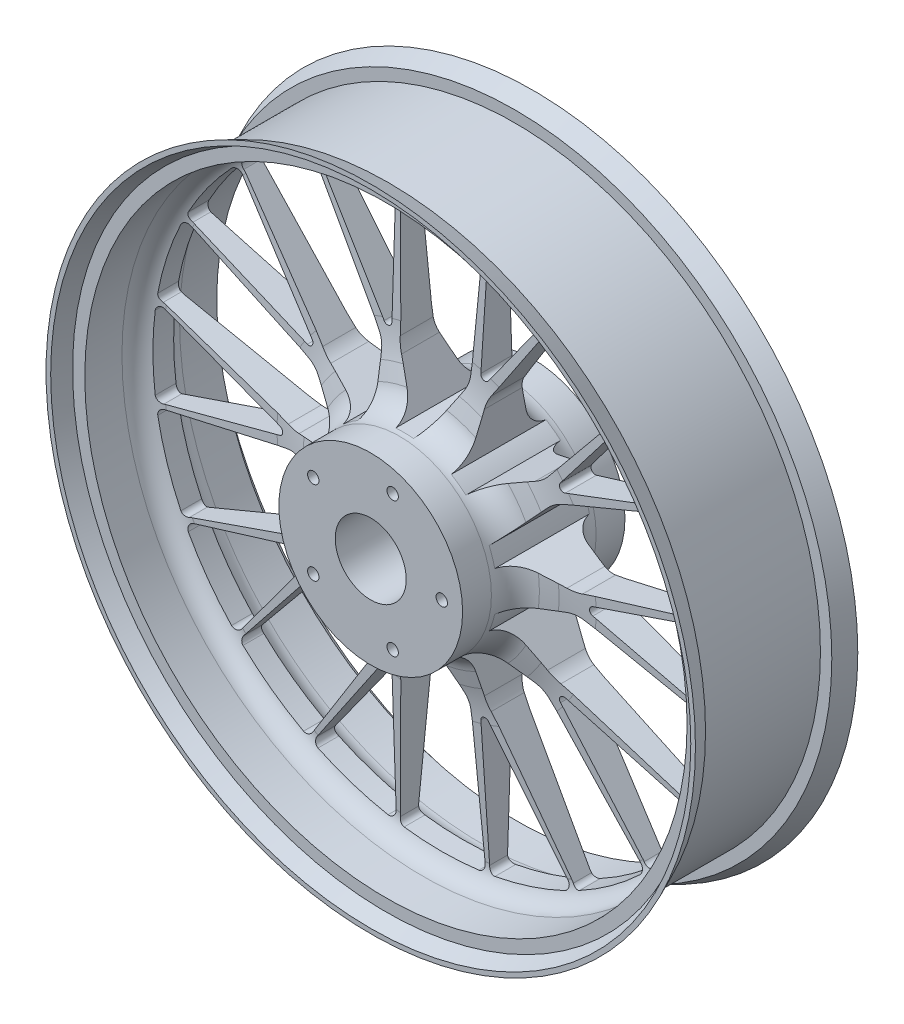
from build123d import *

# Parameters (mm, degrees)
SKETCH1_R           = 228.6
SKETCH1_R_2         = 25
SKETCH1_R_3         = 4
BOSS_EXTRUDE1_DEPTH = 57.15


with BuildPart() as part:
    # Sketch1 → Boss-Extrude1 (new body, symmetric)
    with BuildSketch(Plane.XY):
        Circle(SKETCH1_R)
        Circle(SKETCH1_R_2, mode=Mode.SUBTRACT)
        with Locations((15.45085, 47.552826)):
            Circle(SKETCH1_R_3, mode=Mode.SUBTRACT)
        with Locations((50, 0)):
            Circle(SKETCH1_R_3, mode=Mode.SUBTRACT)
        with Locations((15.45085, -47.552826)):
            Circle(SKETCH1_R_3, mode=Mode.SUBTRACT)
        with Locations((-40.45085, -29.389263)):
            Circle(SKETCH1_R_3, mode=Mode.SUBTRACT)
        with Locations((-40.45085, 29.389263)):
            Circle(SKETCH1_R_3, mode=Mode.SUBTRACT)
        with BuildLine():
            Line((-29.808072, 197.311036), (-24.75602, 100.912126))
            ThreePointArc((-24.75602, 100.912126), (-23.959824, 96.278538), (-22.103937, 91.958845))
            Line((-22.103937, 91.958845), (-6.35921, 64.688179))
            ThreePointArc((-6.35921, 64.688179), (0, 65), (6.35921, 64.688179))
            Line((6.35921, 64.688179), (22.103937, 91.958845))
            ThreePointArc((22.103937, 91.958845), (23.959824, 96.278538), (24.75602, 100.912126))
            Line((24.75602, 100.912126), (29.808072, 197.311036))
            ThreePointArc((29.808072, 197.311036), (28.887709, 200.079593), (26.331899, 201.486652))
            ThreePointArc((26.331899, 201.486652), (0, 203.2), (-26.331899, 201.486652))
            ThreePointArc((-26.331899, 201.486652), (-28.887709, 200.079593), (-29.808072, 197.311036))
        make_face(mode=Mode.SUBTRACT)
        with BuildLine():
            Line((91.86128, 177.148727), (39.286619, 96.190848))
            ThreePointArc((39.286619, 96.190848), (37.2072, 91.974204), (36.169592, 87.388636))
            Line((36.169592, 87.388636), (32.878048, 56.071686))
            ThreePointArc((32.878048, 56.071686), (38.206041, 52.586105), (43.167467, 48.595986))
            Line((43.167467, 48.595986), (71.934513, 61.4039))
            ThreePointArc((71.934513, 61.4039), (75.975009, 63.807742), (79.3427, 67.088401))
            Line((79.3427, 67.088401), (140.091754, 142.107236))
            ThreePointArc((140.091754, 142.107236), (140.974482, 144.888022), (139.733836, 147.528624))
            ThreePointArc((139.733836, 147.528624), (119.437963, 164.392253), (97.127929, 178.483628))
            ThreePointArc((97.127929, 178.483628), (94.233187, 178.84756), (91.86128, 177.148727))
        make_face(mode=Mode.SUBTRACT)
        with BuildLine():
            Line((-31.301343, 105.619631), (-32.875918, 195.826934))
            ThreePointArc((-32.875918, 195.826934), (-34.34903, 198.858401), (-37.615776, 199.68799))
            ThreePointArc((-37.615776, 199.68799), (-62.772389, 193.261137), (-86.904095, 183.678846))
            ThreePointArc((-86.904095, 183.678846), (-89.059737, 181.088459), (-88.471019, 177.770281))
            Line((-88.471019, 177.770281), (-36.758343, 103.846544))
            ThreePointArc((-36.758343, 103.846544), (-35.2528, 102.722302), (-33.373835, 102.714104))
            ThreePointArc((-33.373835, 102.714104), (-31.85854, 103.825164), (-31.301343, 105.619631))
        make_face(mode=Mode.SUBTRACT)
        with BuildLine():
            Line((36.758343, 103.846544), (88.507008, 177.751297))
            ThreePointArc((88.507008, 177.751297), (89.097086, 181.069679), (86.941853, 183.660976))
            ThreePointArc((86.941853, 183.660976), (62.812117, 193.248229), (37.656827, 199.680253))
            ThreePointArc((37.656827, 199.680253), (34.390285, 198.851641), (32.916192, 195.821138))
            Line((32.916192, 195.821138), (31.301343, 105.619631))
            ThreePointArc((31.301343, 105.619631), (31.85854, 103.825164), (33.373835, 102.714104))
            ThreePointArc((33.373835, 102.714104), (35.2528, 102.722302), (36.758343, 103.846544))
        make_face(mode=Mode.SUBTRACT)
        with BuildLine():
            Line((178.442745, 89.321625), (88.323104, 54.727936))
            ThreePointArc((88.323104, 54.727936), (84.162338, 52.538851), (80.627566, 49.438939))
            Line((80.627566, 49.438939), (59.55701, 26.037715))
            ThreePointArc((59.55701, 26.037715), (61.818674, 20.086105), (63.487218, 13.941778))
            Line((63.487218, 13.941778), (94.288551, 7.394753))
            ThreePointArc((94.288551, 7.394753), (98.970324, 6.964558), (103.623165, 7.639188))
            Line((103.623165, 7.639188), (196.865147, 32.623302))
            ThreePointArc((196.865147, 32.623302), (199.213794, 34.354151), (199.762198, 37.219676))
            ThreePointArc((199.762198, 37.219676), (193.254684, 62.792253), (183.48819, 87.305924))
            ThreePointArc((183.48819, 87.305924), (181.360208, 89.301838), (178.442745, 89.321625))
        make_face(mode=Mode.SUBTRACT)
        with BuildLine():
            Line((90.777591, 62.407607), (176.083264, 91.780706))
            ThreePointArc((176.083264, 91.780706), (178.511144, 94.118494), (178.29065, 97.481712))
            ThreePointArc((178.29065, 97.481712), (164.404529, 119.421065), (147.834121, 139.41059))
            ThreePointArc((147.834121, 139.41059), (144.704387, 140.660254), (141.730536, 139.074977))
            Line((141.730536, 139.074977), (87.40498, 67.049608))
            ThreePointArc((87.40498, 67.049608), (86.801001, 65.270343), (87.373835, 63.480807))
            ThreePointArc((87.373835, 63.480807), (88.898769, 62.383012), (90.777591, 62.407607))
        make_face(mode=Mode.SUBTRACT)
        with BuildLine():
            Line((196.865147, -32.623302), (103.623165, -7.639188))
            ThreePointArc((103.623165, -7.639188), (98.970324, -6.964558), (94.288551, -7.394753))
            Line((94.288551, -7.394753), (63.487218, -13.941778))
            ThreePointArc((63.487218, -13.941778), (61.818674, -20.086105), (59.55701, -26.037715))
            Line((59.55701, -26.037715), (80.627566, -49.438939))
            ThreePointArc((80.627566, -49.438939), (84.162338, -52.538851), (88.323104, -54.727936))
            Line((88.323104, -54.727936), (178.442745, -89.321625))
            ThreePointArc((178.442745, -89.321625), (181.360208, -89.301838), (183.48819, -87.305924))
            ThreePointArc((183.48819, -87.305924), (193.254684, -62.792253), (199.762198, -37.219676))
            ThreePointArc((199.762198, -37.219676), (199.213794, -34.354151), (196.865147, -32.623302))
        make_face(mode=Mode.SUBTRACT)
        with BuildLine():
            Line((110.122885, -2.868914), (196.401699, -29.246995))
            ThreePointArc((196.401699, -29.246995), (199.740012, -28.782757), (201.538478, -25.932253))
            ThreePointArc((201.538478, -25.932253), (203.199999, -0.020887), (201.543805, 25.890821))
            ThreePointArc((201.543805, 25.890821), (199.746331, 28.741432), (196.408632, 29.206901))
            Line((196.408632, 29.206901), (110.122885, 2.868914))
            ThreePointArc((110.122885, 2.868914), (108.588429, 1.784468), (108, 0))
            ThreePointArc((108, 0), (108.588429, -1.784468), (110.122885, -2.868914))
        make_face(mode=Mode.SUBTRACT)
        with BuildLine():
            Line((140.091754, -142.107236), (79.3427, -67.088401))
            ThreePointArc((79.3427, -67.088401), (75.975009, -63.807742), (71.934513, -61.4039))
            Line((71.934513, -61.4039), (43.167467, -48.595986))
            ThreePointArc((43.167467, -48.595986), (38.206041, -52.586105), (32.878048, -56.071686))
            Line((32.878048, -56.071686), (36.169592, -87.388636))
            ThreePointArc((36.169592, -87.388636), (37.2072, -91.974204), (39.286619, -96.190848))
            Line((39.286619, -96.190848), (91.86128, -177.148727))
            ThreePointArc((91.86128, -177.148727), (94.233187, -178.84756), (97.127929, -178.483628))
            ThreePointArc((97.127929, -178.483628), (119.437963, -164.392253), (139.733836, -147.528624))
            ThreePointArc((139.733836, -147.528624), (140.974482, -144.888022), (140.091754, -142.107236))
        make_face(mode=Mode.SUBTRACT)
        with BuildLine():
            Line((87.40498, -67.049608), (141.70136, -139.103338))
            ThreePointArc((141.70136, -139.103338), (144.674984, -140.689972), (147.805458, -139.440979))
            ThreePointArc((147.805458, -139.440979), (164.379976, -119.45486), (178.270606, -97.518362))
            ThreePointArc((178.270606, -97.518362), (178.491966, -94.155641), (176.065307, -91.817218))
            Line((176.065307, -91.817218), (90.777591, -62.407607))
            ThreePointArc((90.777591, -62.407607), (88.898769, -62.383012), (87.373835, -63.480807))
            ThreePointArc((87.373835, -63.480807), (86.801001, -65.270343), (87.40498, -67.049608))
        make_face(mode=Mode.SUBTRACT)
        with BuildLine():
            Line((29.808072, -197.311036), (24.75602, -100.912126))
            ThreePointArc((24.75602, -100.912126), (23.959824, -96.278538), (22.103937, -91.958845))
            Line((22.103937, -91.958845), (6.35921, -64.688179))
            ThreePointArc((6.35921, -64.688179), (0, -65), (-6.35921, -64.688179))
            Line((-6.35921, -64.688179), (-22.103937, -91.958845))
            ThreePointArc((-22.103937, -91.958845), (-23.959824, -96.278538), (-24.75602, -100.912126))
            Line((-24.75602, -100.912126), (-29.808072, -197.311036))
            ThreePointArc((-29.808072, -197.311036), (-28.887709, -200.079593), (-26.331899, -201.486652))
            ThreePointArc((-26.331899, -201.486652), (0, -203.2), (26.331899, -201.486652))
            ThreePointArc((26.331899, -201.486652), (28.887709, -200.079593), (29.808072, -197.311036))
        make_face(mode=Mode.SUBTRACT)
        with BuildLine():
            Line((31.301343, -105.619631), (32.875918, -195.826934))
            ThreePointArc((32.875918, -195.826934), (34.34903, -198.858401), (37.615776, -199.68799))
            ThreePointArc((37.615776, -199.68799), (62.772389, -193.261137), (86.904095, -183.678846))
            ThreePointArc((86.904095, -183.678846), (89.059737, -181.088459), (88.471019, -177.770281))
            Line((88.471019, -177.770281), (36.758343, -103.846544))
            ThreePointArc((36.758343, -103.846544), (35.2528, -102.722302), (33.373835, -102.714104))
            ThreePointArc((33.373835, -102.714104), (31.85854, -103.825164), (31.301343, -105.619631))
        make_face(mode=Mode.SUBTRACT)
        with BuildLine():
            Line((-91.86128, -177.148727), (-39.286619, -96.190848))
            ThreePointArc((-39.286619, -96.190848), (-37.2072, -91.974204), (-36.169592, -87.388636))
            Line((-36.169592, -87.388636), (-32.878048, -56.071686))
            ThreePointArc((-32.878048, -56.071686), (-38.206041, -52.586105), (-43.167467, -48.595986))
            Line((-43.167467, -48.595986), (-71.934513, -61.4039))
            ThreePointArc((-71.934513, -61.4039), (-75.975009, -63.807742), (-79.3427, -67.088401))
            Line((-79.3427, -67.088401), (-140.091754, -142.107236))
            ThreePointArc((-140.091754, -142.107236), (-140.974482, -144.888022), (-139.733836, -147.528624))
            ThreePointArc((-139.733836, -147.528624), (-119.437963, -164.392253), (-97.127929, -178.483628))
            ThreePointArc((-97.127929, -178.483628), (-94.233187, -178.84756), (-91.86128, -177.148727))
        make_face(mode=Mode.SUBTRACT)
        with BuildLine():
            Line((-36.758343, -103.846544), (-88.507008, -177.751297))
            ThreePointArc((-88.507008, -177.751297), (-89.097086, -181.069679), (-86.941853, -183.660976))
            ThreePointArc((-86.941853, -183.660976), (-62.812117, -193.248229), (-37.656827, -199.680253))
            ThreePointArc((-37.656827, -199.680253), (-34.390285, -198.851641), (-32.916192, -195.821138))
            Line((-32.916192, -195.821138), (-31.301343, -105.619631))
            ThreePointArc((-31.301343, -105.619631), (-31.85854, -103.825164), (-33.373835, -102.714104))
            ThreePointArc((-33.373835, -102.714104), (-35.2528, -102.722302), (-36.758343, -103.846544))
        make_face(mode=Mode.SUBTRACT)
        with BuildLine():
            Line((-178.442745, -89.321625), (-88.323104, -54.727936))
            ThreePointArc((-88.323104, -54.727936), (-84.162338, -52.538851), (-80.627566, -49.438939))
            Line((-80.627566, -49.438939), (-59.55701, -26.037715))
            ThreePointArc((-59.55701, -26.037715), (-61.818674, -20.086105), (-63.487218, -13.941778))
            Line((-63.487218, -13.941778), (-94.288551, -7.394753))
            ThreePointArc((-94.288551, -7.394753), (-98.970324, -6.964558), (-103.623165, -7.639188))
            Line((-103.623165, -7.639188), (-196.865147, -32.623302))
            ThreePointArc((-196.865147, -32.623302), (-199.213794, -34.354151), (-199.762198, -37.219676))
            ThreePointArc((-199.762198, -37.219676), (-193.254684, -62.792253), (-183.48819, -87.305924))
            ThreePointArc((-183.48819, -87.305924), (-181.360208, -89.301838), (-178.442745, -89.321625))
        make_face(mode=Mode.SUBTRACT)
        with BuildLine():
            Line((-90.777591, -62.407607), (-176.083264, -91.780706))
            ThreePointArc((-176.083264, -91.780706), (-178.511144, -94.118494), (-178.29065, -97.481712))
            ThreePointArc((-178.29065, -97.481712), (-164.404529, -119.421065), (-147.834121, -139.41059))
            ThreePointArc((-147.834121, -139.41059), (-144.704387, -140.660254), (-141.730536, -139.074977))
            Line((-141.730536, -139.074977), (-87.40498, -67.049608))
            ThreePointArc((-87.40498, -67.049608), (-86.801001, -65.270343), (-87.373835, -63.480807))
            ThreePointArc((-87.373835, -63.480807), (-88.898769, -62.383012), (-90.777591, -62.407607))
        make_face(mode=Mode.SUBTRACT)
        with BuildLine():
            Line((-196.865147, 32.623302), (-103.623165, 7.639188))
            ThreePointArc((-103.623165, 7.639188), (-98.970324, 6.964558), (-94.288551, 7.394753))
            Line((-94.288551, 7.394753), (-63.487218, 13.941778))
            ThreePointArc((-63.487218, 13.941778), (-61.818674, 20.086105), (-59.55701, 26.037715))
            Line((-59.55701, 26.037715), (-80.627566, 49.438939))
            ThreePointArc((-80.627566, 49.438939), (-84.162338, 52.538851), (-88.323104, 54.727936))
            Line((-88.323104, 54.727936), (-178.442745, 89.321625))
            ThreePointArc((-178.442745, 89.321625), (-181.360208, 89.301838), (-183.48819, 87.305924))
            ThreePointArc((-183.48819, 87.305924), (-193.254684, 62.792253), (-199.762198, 37.219676))
            ThreePointArc((-199.762198, 37.219676), (-199.213794, 34.354151), (-196.865147, 32.623302))
        make_face(mode=Mode.SUBTRACT)
        with BuildLine():
            Line((-110.122885, 2.868914), (-196.401699, 29.246995))
            ThreePointArc((-196.401699, 29.246995), (-199.740012, 28.782757), (-201.538478, 25.932253))
            ThreePointArc((-201.538478, 25.932253), (-203.199999, 0.020887), (-201.543805, -25.890821))
            ThreePointArc((-201.543805, -25.890821), (-199.746331, -28.741432), (-196.408632, -29.206901))
            Line((-196.408632, -29.206901), (-110.122885, -2.868914))
            ThreePointArc((-110.122885, -2.868914), (-108.588429, -1.784468), (-108, 0))
            ThreePointArc((-108, 0), (-108.588429, 1.784468), (-110.122885, 2.868914))
        make_face(mode=Mode.SUBTRACT)
        with BuildLine():
            Line((-140.091754, 142.107236), (-79.3427, 67.088401))
            ThreePointArc((-79.3427, 67.088401), (-75.975009, 63.807742), (-71.934513, 61.4039))
            Line((-71.934513, 61.4039), (-43.167467, 48.595986))
            ThreePointArc((-43.167467, 48.595986), (-38.206041, 52.586105), (-32.878048, 56.071686))
            Line((-32.878048, 56.071686), (-36.169592, 87.388636))
            ThreePointArc((-36.169592, 87.388636), (-37.2072, 91.974204), (-39.286619, 96.190848))
            Line((-39.286619, 96.190848), (-91.86128, 177.148727))
            ThreePointArc((-91.86128, 177.148727), (-94.233187, 178.84756), (-97.127929, 178.483628))
            ThreePointArc((-97.127929, 178.483628), (-119.437963, 164.392253), (-139.733836, 147.528624))
            ThreePointArc((-139.733836, 147.528624), (-140.974482, 144.888022), (-140.091754, 142.107236))
        make_face(mode=Mode.SUBTRACT)
        with BuildLine():
            Line((-87.40498, 67.049608), (-141.70136, 139.103338))
            ThreePointArc((-141.70136, 139.103338), (-144.674984, 140.689972), (-147.805458, 139.440979))
            ThreePointArc((-147.805458, 139.440979), (-164.379976, 119.45486), (-178.270606, 97.518362))
            ThreePointArc((-178.270606, 97.518362), (-178.491966, 94.155641), (-176.065307, 91.817218))
            Line((-176.065307, 91.817218), (-90.777591, 62.407607))
            ThreePointArc((-90.777591, 62.407607), (-88.898769, 62.383012), (-87.373835, 63.480807))
            ThreePointArc((-87.373835, 63.480807), (-86.801001, 65.270343), (-87.40498, 67.049608))
        make_face(mode=Mode.SUBTRACT)
    extrude(amount=BOSS_EXTRUDE1_DEPTH, both=True)

    # Sketch2 → Cut-Revolve1 (revolve, cut)
    with BuildSketch(Plane(origin=(0, 0, 0), x_dir=(0, 0, -1), z_dir=(1, 0, 0))):
        with BuildLine():
            Line((-6.35, 197.311036), (-10.80576, 112.290072))
            ThreePointArc((-10.80576, 112.290072), (-12.040153, 101.018907), (-14.542544, 89.959932))
            Line((-14.542544, 89.959932), (-17.63495, 79.175431))
            ThreePointArc((-17.63495, 79.175431), (-24.823883, 68.715468), (-36.860184, 64.688179))
            Line((-36.860184, 64.688179), (-57.15, 64.688179))
            Line((-57.15, 64.688179), (-57.15, 225.321297))
            Line((-57.15, 225.321297), (-46.45, 220.603187))
            Line((-46.45, 220.603187), (-46.45, 212))
            Line((-46.45, 212), (-20.289306, 212))
            ThreePointArc((-20.289306, 212), (-10.164215, 207.649917), (-6.35, 197.311036))
        make_face()
        Polygon((-57.15, 228.6), (57.15, 228.6), (44.45, 223), (44.45, 215), (-44.45, 215), (-44.45, 223), align=None)
        with BuildLine():
            Line((46.45, 220.603187), (46.45, 212))
            Line((46.45, 212), (20.289306, 212))
            ThreePointArc((20.289306, 212), (10.164215, 207.649917), (6.35, 197.311036))
            Line((6.35, 197.311036), (10.80576, 112.290072))
            ThreePointArc((10.80576, 112.290072), (12.040153, 101.018907), (14.542544, 89.959932))
            Line((14.542544, 89.959932), (17.63495, 79.175431))
            ThreePointArc((17.63495, 79.175431), (24.823883, 68.715468), (36.860184, 64.688179))
            Line((36.860184, 64.688179), (57.15, 64.688179))
            Line((57.15, 64.688179), (57.15, 225.321297))
            Line((57.15, 225.321297), (46.45, 220.603187))
        make_face()
    revolve(axis=Axis((0, 0, 0), (0, 0, -1)), mode=Mode.SUBTRACT)


solid = part.part
